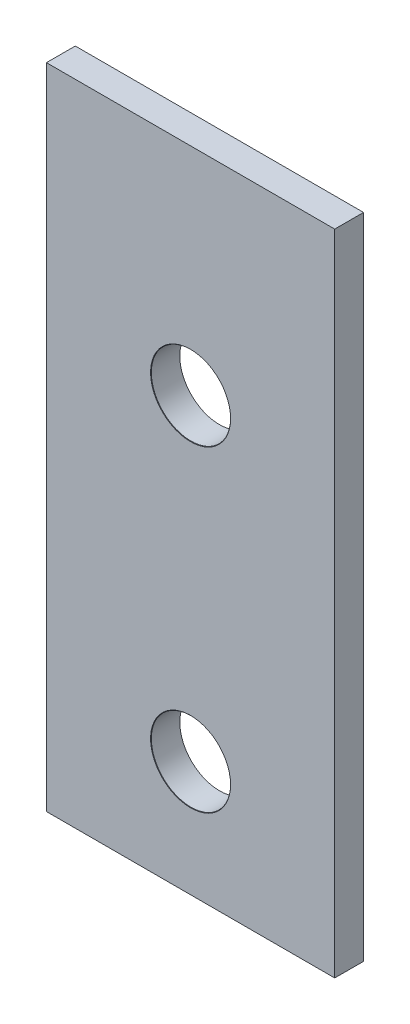
from build123d import *

# Parameters (mm, degrees)
SKETCH1_W                     = 20
SKETCH1_H                     = 45
BOSS_EXTRUDE1_DEPTH           = 2
M5_CLEARANCE_HOLE1_AT_2_COUNT = 2
M5_CLEARANCE_HOLE1_AT_2_PITCH = 22


with BuildPart() as part:
    # Sketch1 → Boss-Extrude1 (new body)
    with BuildSketch(Plane.XY):
        with Locations((10, 22.5)):
            Rectangle(SKETCH1_W, SKETCH1_H)
    extrude(amount=BOSS_EXTRUDE1_DEPTH)

    # Sketch3 → M5 Clearance Hole1 (revolve, cut)
    with BuildSketch(Plane(origin=(10, 30, 2), x_dir=(0, -1, 0), z_dir=(1, 0, 0))):
        Polygon((0, 0), (0, 2), (2.75, 2), (2.75, 0.025), (2.775, 0), align=None)
    m5_clearance_hole1 = revolve(axis=Axis((10, 30, 8.35), (0, 0, -1)), mode=Mode.SUBTRACT)

    # M5 Clearance Hole1 at 2: M5 Clearance Hole1 ×2
    with Locations(*[(0, -i * M5_CLEARANCE_HOLE1_AT_2_PITCH, 0) for i in range(1, M5_CLEARANCE_HOLE1_AT_2_COUNT)]):
        add(m5_clearance_hole1, mode=Mode.SUBTRACT)


solid = part.part
